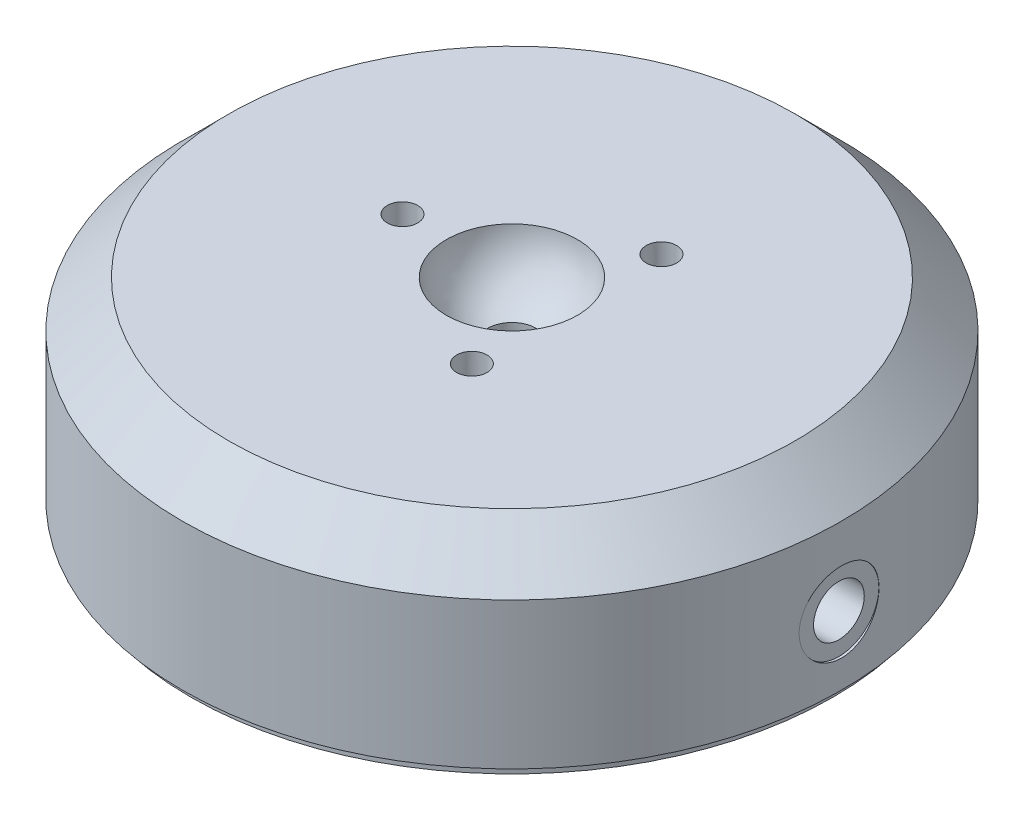
from build123d import *

# Parameters (mm, degrees)
SKETCH1_R                       = 32.5
EXTRUDE1_DEPTH                  = 18.9992
CHAMFER1_SIZE                   = 4.57
M3X0_5_TAPPED_HOLE3_D           = 2.5
M3X0_5_TAPPED_HOLE3_DEPTH       = 7.8486
M3X0_5_TAPPED_HOLE3_CBORE_D     = 3
M3X0_5_TAPPED_HOLE3_CBORE_DEPTH = 6.35
M3X0_5_TAPPED_HOLE3_TIP         = 0.751075774
M5X0_8_TAPPED_HOLE1_D           = 4.2
M5X0_8_TAPPED_HOLE1_DEPTH       = 27.94
M5X0_8_TAPPED_HOLE1_CBORE_D     = 5
M5X0_8_TAPPED_HOLE1_CBORE_DEPTH = 7.62
M5X0_8_TAPPED_HOLE1_TIP         = 1.2618073
HOLE1_D                         = 3.048
HOLE1_DEPTH                     = 6.35
HOLE1_CBORE_D                   = 7.874
HOLE1_CBORE_DEPTH               = 0.254
HOLE1_TIP                       = 0.915711583
SKETCH2_R                       = 31.6865
EXTRUDE2_DEPTH                  = 1.00076


with BuildPart() as part:
    # Sketch1 → Extrude1 (new body)
    with BuildSketch(Plane(origin=(0, 0, 0), x_dir=(1, 0, 0), z_dir=(0, 1, 0))):
        with Locations(Location((0, 0, 0), (0, 0, 270))):  # turned: the seam where the file's is
            Circle(SKETCH1_R)
    extrude(amount=EXTRUDE1_DEPTH)

    # Sketch3 → Cut-Revolve1 (revolve, cut)
    with BuildSketch(Plane.XY, mode=Mode.PRIVATE) as cut_revolve1_sk:
        with BuildLine():
            Line((2.3876, 13.463763428), (2.3876, 12.7508))
            Line((2.3876, 12.7508), (0, 12.7508))
            Line((0, 12.7508), (0, 18.9992))
            Line((0, 18.9992), (6.470525878, 18.9992))
            ThreePointArc((6.470525878, 18.9992), (5.220905936, 15.647420055), (2.3876, 13.463763428))
        make_face()
    revolve(cut_revolve1_sk.sketch.rotate(Axis((0, 18.9992, 0), (0, -1, 0)), 90), axis=Axis((0, 18.9992, 0), (0, -1, 0)), mode=Mode.SUBTRACT)  # turned: the seam where the file's is

    # Chamfer1
    chamfer1_edges = [part.edges().sort_by_distance(p)[0] for p in [
        (0, 18.9992, -32.5),
    ]]
    chamfer(chamfer1_edges, length=CHAMFER1_SIZE)

    # M3x0.5 Tapped Hole3
    with Locations(Plane(origin=(0, 18.9992, 0), x_dir=(-1, 0, 0), z_dir=(0, 1, 0))):
        with Locations((-5.3975, -9.348744234), (10.795, 0), (-5.3975, 9.348744234)):
            CounterBoreHole(M3X0_5_TAPPED_HOLE3_D / 2, M3X0_5_TAPPED_HOLE3_CBORE_D / 2, M3X0_5_TAPPED_HOLE3_CBORE_DEPTH, depth=M3X0_5_TAPPED_HOLE3_DEPTH)
            with Locations((0, 0, -(M3X0_5_TAPPED_HOLE3_DEPTH + M3X0_5_TAPPED_HOLE3_TIP / 2))):  # 118° drill point
                Cone(0, M3X0_5_TAPPED_HOLE3_D / 2, M3X0_5_TAPPED_HOLE3_TIP, mode=Mode.SUBTRACT)

    # M5x0.8 Tapped Hole1
    with Locations(Plane(origin=(32.5, 6.6802, 0), x_dir=(0, 0, 1), z_dir=(1, 0, 0))):
        with Locations((0, 0)):
            CounterBoreHole(M5X0_8_TAPPED_HOLE1_D / 2, M5X0_8_TAPPED_HOLE1_CBORE_D / 2, M5X0_8_TAPPED_HOLE1_CBORE_DEPTH, depth=M5X0_8_TAPPED_HOLE1_DEPTH)
            with Locations((0, 0, -(M5X0_8_TAPPED_HOLE1_DEPTH + M5X0_8_TAPPED_HOLE1_TIP / 2))):  # 118° drill point
                Cone(0, M5X0_8_TAPPED_HOLE1_D / 2, M5X0_8_TAPPED_HOLE1_TIP, mode=Mode.SUBTRACT)

    # Hole1
    with Locations(Plane(origin=(32.5, 6.6802, 0), x_dir=(0, 0, 1), z_dir=(1, 0, 0))):
        with Locations((0, 0)):
            CounterBoreHole(HOLE1_D / 2, HOLE1_CBORE_D / 2, HOLE1_CBORE_DEPTH, depth=HOLE1_DEPTH)
            with Locations((0, 0, -(HOLE1_DEPTH + HOLE1_TIP / 2))):  # 118° drill point
                Cone(0, HOLE1_D / 2, HOLE1_TIP, mode=Mode.SUBTRACT)

    # Sketch2 → Extrude2 (add)
    with BuildSketch(Plane.XZ):
        with Locations(Location((0, 0, 0), (0, 0, 90))):  # turned: the seam where the file's is
            Circle(SKETCH2_R)
    extrude(amount=EXTRUDE2_DEPTH)


solid = part.part
